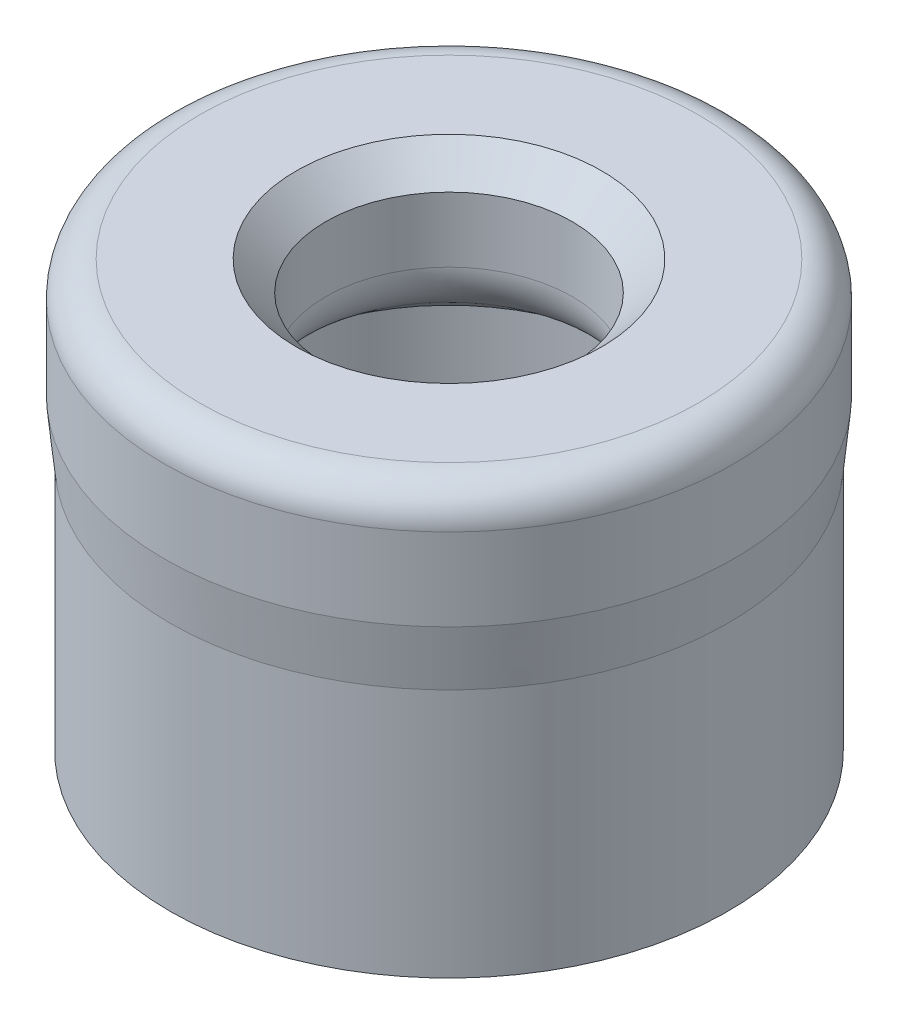
from build123d import *

# Parameters (mm, degrees)
CROQUIS1_R              = 4.75
CROQUIS1_R_2            = 3.275
SALIENTE_EXTRUIR1_DEPTH = 4.25
CROQUIS3_R              = 4.85
CROQUIS3_R_2            = 2.1
SALIENTE_EXTRUIR2_DEPTH = 2
REDONDEO1_R             = 0.6
REDONDEO2_R             = 1
CHAFL_N1_SIZE           = 0.7
CHAFL_N2_SIZE           = 0.5


with BuildPart() as part:
    # Croquis1 → Saliente-Extruir1 (new body)
    with BuildSketch(Plane(origin=(0, 0, 0), x_dir=(1, 0, 0), z_dir=(0, 1, 0))):
        Circle(CROQUIS1_R)
        Circle(CROQUIS1_R_2, mode=Mode.SUBTRACT)
    extrude(amount=SALIENTE_EXTRUIR1_DEPTH)

    # Croquis2 → Revolución1 (revolve)
    with BuildSketch(Plane.XY):
        Polygon((-4.75, 4.25), (-4.85, 5.25), (-2.1, 5.25), (-2.1, 5.15), (-3.275, 4.25), align=None)
    revolve(axis=Axis((0, 0, 0), (0, 1, 0)))

    # Croquis3 → Saliente-Extruir2 (add)
    with BuildSketch(Plane(origin=(0, 5.25, 0), x_dir=(1, 0, 0), z_dir=(0, 1, 0))):
        Circle(CROQUIS3_R)
        Circle(CROQUIS3_R_2, mode=Mode.SUBTRACT)
    extrude(amount=SALIENTE_EXTRUIR2_DEPTH)

    # Redondeo1
    redondeo1_edges = [part.edges().sort_by_distance(p)[0] for p in [
        (-4.85, 7.25, 0),
    ]]
    fillet(redondeo1_edges, radius=REDONDEO1_R)

    # Redondeo2
    redondeo2_edges = [part.edges().sort_by_distance(p)[0] for p in [
        (2.1, 5.15, 0),
    ]]
    fillet(redondeo2_edges, radius=REDONDEO2_R)

    # Chaflán1
    chafl_n1_edges = [part.edges().sort_by_distance(p)[0] for p in [
        (-3.275, 0, 0),
    ]]
    chamfer(chafl_n1_edges, length=CHAFL_N1_SIZE)

    # Chaflán2
    chafl_n2_edges = [part.edges().sort_by_distance(p)[0] for p in [
        (-2.1, 7.25, 0),
    ]]
    chamfer(chafl_n2_edges, length=CHAFL_N2_SIZE)


solid = part.part
